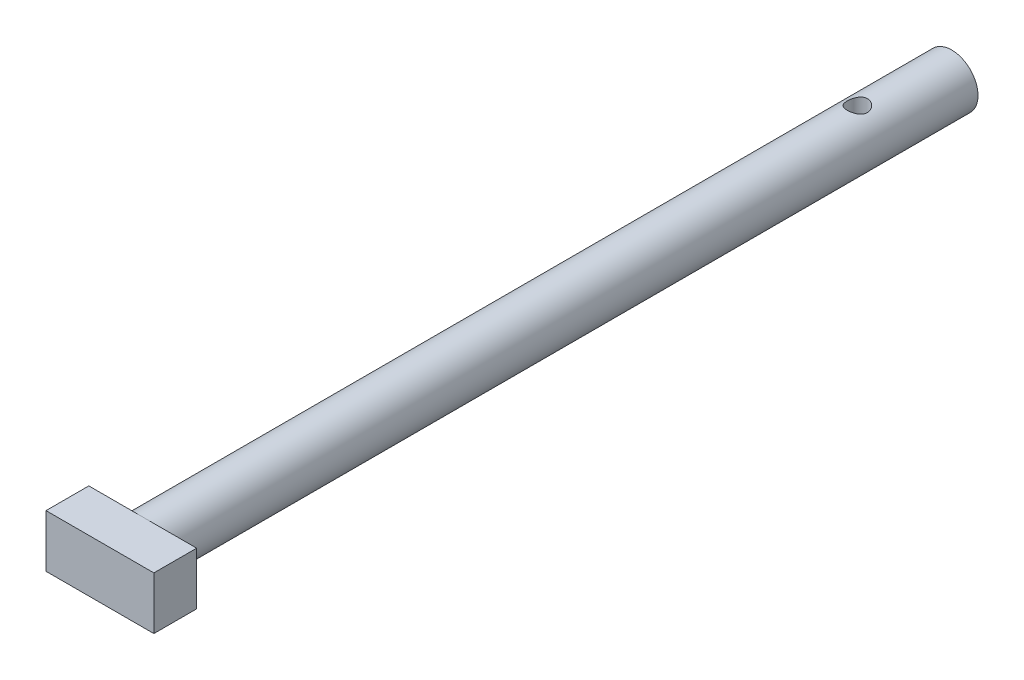
from build123d import *

# Parameters (mm, degrees)
SKETCH1_R           = 1.95
BOSS_EXTRUDE1_DEPTH = 60
SKETCH2_W           = 8
SKETCH2_H           = 3.9
BOSS_EXTRUDE2_DEPTH = 3.175
SKETCH3_R           = 0.75
CUT_EXTRUDE1_DEPTH  = 5


with BuildPart() as part:
    # Sketch1 → Boss-Extrude1 (new body)
    with BuildSketch(Plane.XY):
        Circle(SKETCH1_R)
    extrude(amount=BOSS_EXTRUDE1_DEPTH)

    # Sketch2 → Boss-Extrude2 (add)
    with BuildSketch(Plane.XY.offset(60)):
        Rectangle(SKETCH2_W, SKETCH2_H)
    extrude(amount=BOSS_EXTRUDE2_DEPTH)

    # Sketch3 → Cut-Extrude1 (cut)
    with BuildSketch(Plane(origin=(0, 1.95, 0), x_dir=(1, 0, 0), z_dir=(0, 1, 0))):
        with Locations((0, -7)):
            Circle(SKETCH3_R)
    extrude(amount=-CUT_EXTRUDE1_DEPTH, mode=Mode.SUBTRACT)


solid = part.part
